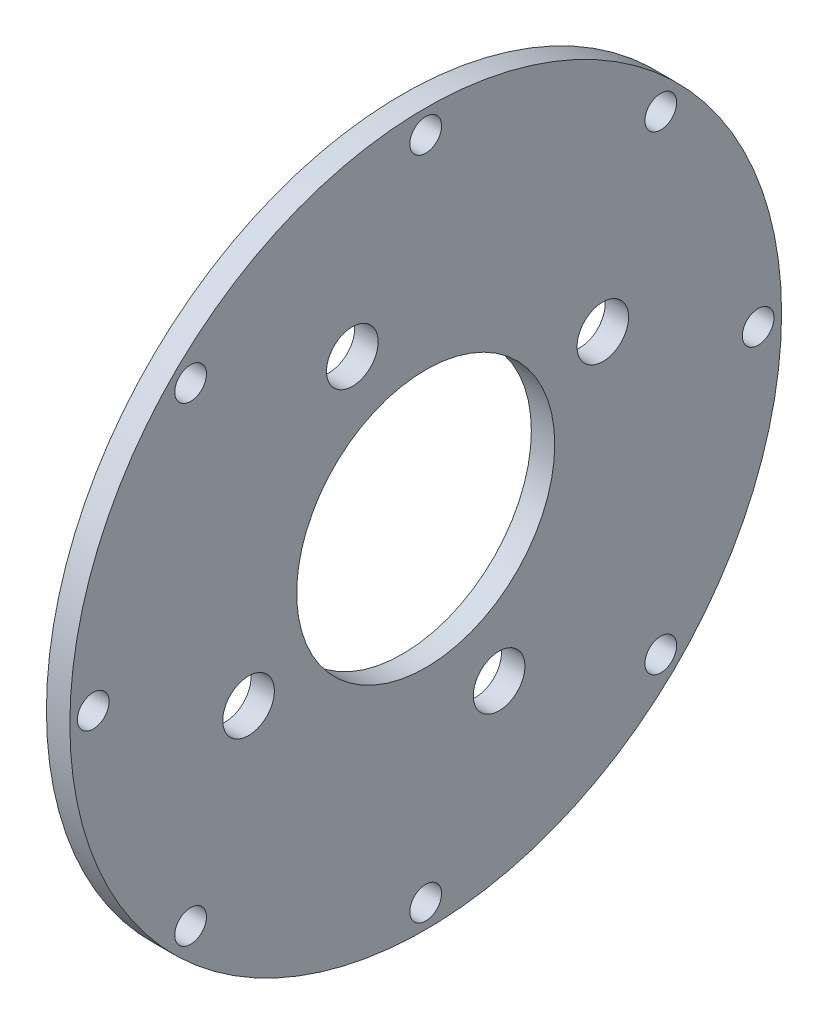
from build123d import *

# Parameters (mm, degrees)
SKETCH1_R           = 48.26
SKETCH1_R_2         = 2.15265
SKETCH1_R_3         = 3.5
SKETCH1_R_4         = 17.5
BOSS_EXTRUDE1_DEPTH = 3.175


with BuildPart() as part:
    # Sketch1 → Boss-Extrude1 (new body)
    with BuildSketch(Plane(origin=(0, 0, 0), x_dir=(0, 0, -1), z_dir=(1, 0, 0))):
        Circle(SKETCH1_R)
        with Locations((0, 45.085)):
            Circle(SKETCH1_R_2, mode=Mode.SUBTRACT)
        with Locations((-24.023795501, -9.950801949)):
            Circle(SKETCH1_R_3, mode=Mode.SUBTRACT)
        with Locations((31.87990923, 31.87990923)):
            Circle(SKETCH1_R_2, mode=Mode.SUBTRACT)
        with Locations((45.085, 0)):
            Circle(SKETCH1_R_2, mode=Mode.SUBTRACT)
        with Locations((24.018239985, 9.948012748)):
            Circle(SKETCH1_R_3, mode=Mode.SUBTRACT)
        with Locations((-9.9503853, 24.023968076)):
            Circle(SKETCH1_R_3, mode=Mode.SUBTRACT)
        with Locations((31.87990923, -31.87990923)):
            Circle(SKETCH1_R_2, mode=Mode.SUBTRACT)
        with Locations((0, -45.085)):
            Circle(SKETCH1_R_2, mode=Mode.SUBTRACT)
        with Locations((-31.87990923, -31.87990923)):
            Circle(SKETCH1_R_2, mode=Mode.SUBTRACT)
        with Locations((-45.085, 0)):
            Circle(SKETCH1_R_2, mode=Mode.SUBTRACT)
        with Locations((-31.87990923, 31.87990923)):
            Circle(SKETCH1_R_2, mode=Mode.SUBTRACT)
        Circle(SKETCH1_R_4, mode=Mode.SUBTRACT)
        with Locations((9.950974523, -24.02421215)):
            Circle(SKETCH1_R_3, mode=Mode.SUBTRACT)
    extrude(amount=BOSS_EXTRUDE1_DEPTH)


solid = part.part
